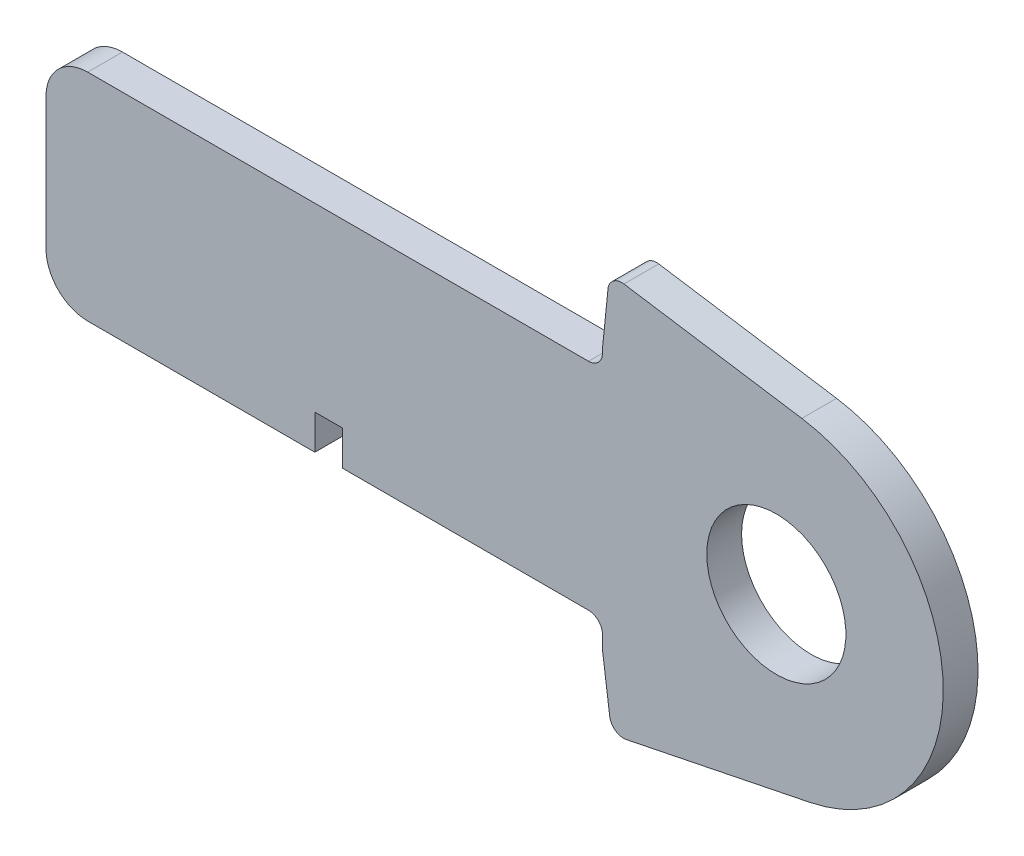
from build123d import *

# Parameters (mm, degrees)
BOSS_EXTRUDE1_DEPTH = 3.175
CUT_EXTRUDE1_DEPTH  = 7.62
SKETCH3_R           = 6.35
CUT_EXTRUDE2_DEPTH  = 7.62
CUT_EXTRUDE3_DEPTH  = 443.627115857
FILLET1_R           = 3.81
FILLET2_R           = 1.27


with BuildPart() as part:
    # Sketch1 → Boss-Extrude1 (new body)
    with BuildSketch(Plane.XY):
        with BuildLine():
            Line((435.33010469, 0.678691456), (439.172882547, -1.614212492))
            Line((439.172882547, -1.614212492), (434.787151486, -0.678691456))
            add(Edge.make_bspline(
                [(0, 0), (0.11179123, -0.527729161), (0.335887463, -1.58561283), (0.94472768, -3.108527015), (1.749889805, -4.572488672), (2.768272335, -5.973609192), (3.993104005, -7.311505618), (5.421679636, -8.587569541), (7.052598221, -9.801114861), (8.883725224, -10.951589231), (10.912400596, -12.040213999), (13.136344152, -13.066312264), (15.553528081, -14.029563428), (18.161318821, -14.928679795), (20.956528242, -15.765030781), (23.936498821, -16.536578215), (27.097842034, -17.244400464), (30.437517266, -17.886690773), (33.951885298, -18.464101669), (37.637295209, -18.976309975), (41.489964184, -19.423636044), (45.506112459, -19.80514129), (49.681767661, -20.121646285), (54.012767863, -20.373360955), (58.494909036, -20.561083494), (63.123897762, -20.684100336), (67.895200479, -20.744329207), (72.804505265, -20.742674403), (77.847009648, -20.678693244), (83.018406129, -20.555920262), (88.313732191, -20.373577887), (93.728207214, -20.133872554), (99.256947275, -19.839216685), (104.89499369, -19.49060908), (110.637384794, -19.089594814), (116.479134607, -18.639389777), (122.414936441, -18.141116951), (128.439613477, -17.597680601), (134.547832047, -17.011801372), (140.734314746, -16.385333349), (146.993600903, -15.721223571), (153.320115485, -15.021624036), (159.708476563, -14.290267097), (166.152848405, -13.528475979), (172.647781594, -12.740600204), (179.187166024, -11.928145018), (185.765533466, -11.094239816), (192.376967293, -10.242811017), (199.015278084, -9.37376151), (205.674882543, -8.493282903), (212.349358377, -7.600650086), (219.032895906, -6.7004538), (225.719308248, -5.795492203), (232.402082768, -4.886043807), (239.075345122, -3.975877517), (245.732904616, -3.06749205), (252.368240069, -2.160970285), (258.975348295, -1.26081803), (265.547576185, -0.366925322), (272.078863439, 0.518895586), (278.562951189, 1.394000598), (284.993721977, 2.257285217), (291.364542133, 3.108203268), (297.66900214, 3.947074317), (303.806375969, 4.748436439), (309.760626579, 5.554962658), (315.551818652, 6.216135275), (321.27090305, 6.780469964), (326.923820465, 7.243146515), (332.503782957, 7.610821489), (338.004397185, 7.886122043), (343.419107553, 8.072891719), (348.74107448, 8.176671364), (353.963650696, 8.200094537), (359.079707468, 8.150631139), (364.082590991, 8.032268225), (368.965318868, 7.850318702), (373.721079318, 7.610921079), (378.343117125, 7.320601554), (382.824493294, 6.983642622), (387.158963185, 6.607910686), (391.339839301, 6.198906082), (395.360701925, 5.761301701), (399.215684034, 5.304267166), (402.898615263, 4.830811549), (406.403955911, 4.348715399), (409.726063296, 3.862864382), (412.859676284, 3.379461168), (415.799871302, 2.903117573), (418.541899149, 2.440155772), (421.081464376, 1.994901374), (423.414160264, 1.571702591), (425.536750687, 1.175899009), (427.445043551, 0.809456817), (429.136486586, 0.478415007), (430.607934716, 0.184234372), (431.857230885, -0.068940506), (432.88219343, -0.280110359), (433.681265576, -0.445808771), (434.252869013, -0.566300363), (434.596385478, -0.637999126), (434.749014267, -0.670556399), (434.787151486, -0.678691456)],
                knots=[0, 0, 0, 0, 0.003638255, 0.007293231, 0.011028136, 0.014901081, 0.018963272, 0.023258475, 0.027820626, 0.032679082, 0.03785316, 0.043361875, 0.049214679, 0.055422346, 0.061988786, 0.068918036, 0.076211157, 0.083868392, 0.091887411, 0.100265912, 0.108999867, 0.118084529, 0.127514843, 0.13728527, 0.147387917, 0.157816481, 0.168563473, 0.179619128, 0.190977373, 0.202626974, 0.214560478, 0.226767249, 0.239236417, 0.251959004, 0.264923894, 0.278119703, 0.291536035, 0.30516028, 0.318980685, 0.332985499, 0.34716279, 0.361498603, 0.375980747, 0.390597192, 0.405332593, 0.420174823, 0.435109533, 0.450124276, 0.465203068, 0.480333154, 0.495500583, 0.510689775, 0.525887334, 0.541078314, 0.556247233, 0.571381785, 0.58646604, 0.601484515, 0.616424329, 0.631269423, 0.646006524, 0.660620684, 0.675098187, 0.689422858, 0.703581825, 0.716907563, 0.730009274, 0.742952128, 0.755725557, 0.768319951, 0.780724337, 0.792926528, 0.804916041, 0.816679084, 0.828203525, 0.8394749, 0.850481359, 0.861207697, 0.871639326, 0.881763414, 0.891563605, 0.901027365, 0.910138977, 0.918883977, 0.927249278, 0.935221104, 0.942784739, 0.949928188, 0.956638465, 0.962904203, 0.968712288, 0.974054485, 0.978918432, 0.983297219, 0.987180246, 0.990560674, 0.993433357, 0.995790626, 0.997629588, 0.998945816, 0.999736592, 1, 1, 1, 1], degree=3))
            add(Edge.make_bspline(
                [(435.33010469, 0.678691456), (435.296755582, 0.699293055), (435.163488681, 0.781619431), (434.863214309, 0.965803828), (434.363194901, 1.272571896), (433.663211466, 1.69979322), (432.763807452, 2.246333125), (431.664530435, 2.908364558), (430.366066728, 3.683736897), (428.86873043, 4.568782589), (427.172675107, 5.559358025), (425.278546429, 6.651449737), (423.186509465, 7.838875427), (420.897374442, 9.116782681), (418.411926851, 10.4790944), (415.730636684, 11.919657082), (412.854464224, 13.43114364), (409.784513475, 15.00705265), (406.521344218, 16.638681918), (403.066494801, 18.319240705), (399.421116368, 20.040349747), (395.586453278, 21.79282696), (391.56470833, 23.569527811), (387.356993489, 25.359407096), (382.965706604, 27.15470981), (378.392717175, 28.945218407), (373.640732922, 30.722778715), (368.711587102, 32.475875028), (363.608964359, 34.196846251), (358.335340013, 35.87451254), (352.894485425, 37.499762392), (347.289561815, 39.062058655), (341.52524157, 40.553388886), (335.605180365, 41.962892679), (329.534395845, 43.28113527), (323.317713598, 44.500180123), (316.960347344, 45.607856696), (310.479914041, 46.603301327), (303.980682286, 47.431342852), (297.494822244, 48.243461645), (291.0186212, 49.006373108), (284.46326746, 49.736966294), (277.835067652, 50.431127833), (271.140596349, 51.086687253), (264.386630807, 51.700815013), (257.580189535, 52.27171033), (250.727858804, 52.796138155), (243.836864005, 53.273290553), (236.914017847, 53.698972807), (229.966694004, 54.072865307), (223.001944897, 54.392360355), (216.027018499, 54.655256617), (209.049321182, 54.859966995), (202.076096041, 55.004530305), (195.114893299, 55.088037667), (188.172953688, 55.108207309), (181.257823923, 55.064678381), (174.376745271, 54.95595632), (167.537272154, 54.780552763), (160.7466557, 54.538140281), (154.012238926, 54.228824112), (147.341395315, 53.850013849), (140.741361553, 53.404123644), (134.219487317, 52.889280335), (127.782938298, 52.305347044), (121.438460058, 51.65475786), (115.193116172, 50.935743156), (109.053599754, 50.150348891), (103.026626206, 49.300114834), (97.118957953, 48.384577869), (91.33692342, 47.406382542), (85.686763085, 46.366529581), (80.174454785, 45.268067638), (74.805999973, 44.111283189), (69.587081438, 42.899646299), (64.52312301, 41.635267927), (59.619568317, 40.320462769), (54.881388132, 38.958385816), (50.313373811, 37.552127128), (45.920850559, 36.103231966), (41.707138151, 34.617193881), (37.677412709, 33.095067788), (33.834761135, 31.541542875), (30.183686712, 29.958740393), (26.726916941, 28.351485511), (23.468364091, 26.721608068), (20.41035055, 25.073674406), (17.555946308, 23.410211446), (14.907899047, 21.73430892), (12.467321746, 20.050217809), (10.237579271, 18.35899521), (8.219437586, 16.664914738), (6.414173801, 14.97055608), (4.824368385, 13.277086383), (3.449964137, 11.587487839), (2.292762263, 9.903098559), (1.352963468, 8.225512409), (0.632693499, 6.555947979), (0.13123808, 4.895344207), (-0.143255259, 3.246152095), (-0.211578297, 1.607049514), (-0.07042072, 0.534882766), (0, 0)],
                knots=[0, 0, 0, 0, 0.00025409, 0.001015373, 0.002283359, 0.004056577, 0.006330982, 0.009105274, 0.012374489, 0.016134023, 0.02037966, 0.025105976, 0.030306237, 0.035972206, 0.042099522, 0.048678064, 0.055701664, 0.063160184, 0.071045824, 0.079349826, 0.08806291, 0.097175756, 0.106678112, 0.116561573, 0.126814275, 0.137428301, 0.148393618, 0.15969976, 0.171338126, 0.183297699, 0.195569604, 0.208143556, 0.221011593, 0.234161831, 0.24758745, 0.261276822, 0.27522271, 0.289414144, 0.303771199, 0.317689227, 0.331784111, 0.346039677, 0.36044387, 0.37498272, 0.389640454, 0.404403316, 0.419256601, 0.434186749, 0.449177265, 0.464214782, 0.479284009, 0.49436974, 0.509457833, 0.524532346, 0.53957932, 0.554582984, 0.569529546, 0.584403417, 0.599190992, 0.613876838, 0.628447475, 0.642888675, 0.657186054, 0.671325546, 0.685294014, 0.699078147, 0.712665095, 0.726042645, 0.739197713, 0.752117586, 0.764792042, 0.777208152, 0.789355685, 0.80122396, 0.812803686, 0.824082909, 0.835054602, 0.845709571, 0.856037853, 0.866033834, 0.875688843, 0.884997719, 0.893953426, 0.902552897, 0.910789386, 0.918660734, 0.926166253, 0.933302626, 0.94007122, 0.94647478, 0.952517526, 0.958204819, 0.963546652, 0.9685566, 0.973249913, 0.977651041, 0.981787043, 0.985694226, 0.989415109, 0.993001157, 0.996508416, 1, 1, 1, 1], degree=3))
        make_face()
    extrude(amount=BOSS_EXTRUDE1_DEPTH)

    # Sketch2 → Cut-Extrude1 (cut)
    with BuildSketch(Plane(origin=(0, 0, 0), x_dir=(-1, 0, 0), z_dir=(0, 0, -1))):
        Polygon((-252.794440989, 13.221493744), (-250.254440989, 13.221493744), (-250.254440989, -2.115243028), (-250.254440989, -3.986349358), (-252.794440989, -3.050796193), (-252.794440989, -2.115243028), align=None)
        Polygon((-159.131940989, 54.422217902), (-159.131940989, 39.039100326), (-152.781940989, 39.039100326), (-152.781940989, 54.422217902), (-152.781940989, 57.645440557), (-159.131940989, 55.540936844), align=None)
        Polygon((-74.994440989, -5.928775484), (-74.994440989, -20.141805429), (-74.994440989, -20.97642061), (-71.819440989, -22.145862066), (-71.819440989, -20.141805429), (-71.819440989, -5.928775484), align=None)
    extrude(amount=-CUT_EXTRUDE1_DEPTH, mode=Mode.SUBTRACT)

    # Sketch3 → Cut-Extrude2 (cut)
    with BuildSketch(Plane(origin=(0, 0, 0), x_dir=(-1, 0, 0), z_dir=(0, 0, -1))):
        with Locations((-292.383806588, 26.255421435)):
            Circle(SKETCH3_R)
    extrude(amount=-CUT_EXTRUDE2_DEPTH, mode=Mode.SUBTRACT)

    # Sketch4 → Cut-Extrude3 (cut, through all)
    with BuildSketch(Plane.XY.offset(3.175)):
        with BuildLine():
            Line((252.794440989, 13.221493744), (252.794440989, -2.10324862))
            add(Edge.make_bspline(
                [(252.794440989, -2.10324862), (254.858559034, -1.821690299), (259.114187798, -1.241934385), (265.547576185, -0.366925322), (272.078863439, 0.518895586), (278.562951189, 1.394000598), (284.993721977, 2.257285217), (291.364542133, 3.108203268), (297.66900214, 3.947074317), (303.806375969, 4.748436439), (309.760626579, 5.554962658), (315.551818652, 6.216135275), (321.27090305, 6.780469964), (326.923820465, 7.243146515), (332.503782957, 7.610821489), (338.004397185, 7.886122043), (343.419107553, 8.072891719), (348.74107448, 8.176671364), (353.963650696, 8.200094537), (359.079707468, 8.150631139), (364.082590991, 8.032268225), (368.965318868, 7.850318702), (373.721079318, 7.610921079), (378.343117125, 7.320601554), (382.824493294, 6.983642622), (387.158963185, 6.607910686), (391.339839301, 6.198906082), (395.360701925, 5.761301701), (399.215684034, 5.304267166), (402.898615263, 4.830811549), (406.403955911, 4.348715399), (409.726063296, 3.862864382), (412.859676284, 3.379461168), (415.799871302, 2.903117573), (418.541899149, 2.440155772), (421.081464376, 1.994901374), (423.414160264, 1.571702591), (425.536750687, 1.175899009), (427.445043551, 0.809456817), (429.136486586, 0.478415007), (430.607934716, 0.184234372), (431.857230885, -0.068940506), (432.88219343, -0.280110359), (433.681265576, -0.445808771), (434.252869013, -0.566300363), (434.596385478, -0.637999126), (434.749014267, -0.670556399), (434.787151486, -0.678691456)],
                knots=[0.58741252, 0.58741252, 0.58741252, 0.58741252, 0.601484515, 0.616424329, 0.631269423, 0.646006524, 0.660620684, 0.675098187, 0.689422858, 0.703581825, 0.716907563, 0.730009274, 0.742952128, 0.755725557, 0.768319951, 0.780724337, 0.792926528, 0.804916041, 0.816679084, 0.828203525, 0.8394749, 0.850481359, 0.861207697, 0.871639326, 0.881763414, 0.891563605, 0.901027365, 0.910138977, 0.918883977, 0.927249278, 0.935221104, 0.942784739, 0.949928188, 0.956638465, 0.962904203, 0.968712288, 0.974054485, 0.978918432, 0.983297219, 0.987180246, 0.990560674, 0.993433357, 0.995790626, 0.997629588, 0.998945816, 0.999736592, 1, 1, 1, 1], degree=3))
            Line((434.787151486, -0.678691456), (439.172882547, -1.614212492))
            Line((439.172882547, -1.614212492), (435.33010469, 0.678691456))
            add(Edge.make_bspline(
                [(435.33010469, 0.678691456), (435.296755582, 0.699293055), (435.163488681, 0.781619431), (434.863214309, 0.965803828), (434.363194901, 1.272571896), (433.663211466, 1.69979322), (432.763807452, 2.246333125), (431.664530435, 2.908364558), (430.366066728, 3.683736897), (428.86873043, 4.568782589), (427.172675107, 5.559358025), (425.278546429, 6.651449737), (423.186509465, 7.838875427), (420.897374442, 9.116782681), (418.411926851, 10.4790944), (415.730636684, 11.919657082), (412.854464224, 13.43114364), (409.784513475, 15.00705265), (406.521344218, 16.638681918), (403.066494801, 18.319240705), (399.421116368, 20.040349747), (395.586453278, 21.79282696), (391.56470833, 23.569527811), (387.356993489, 25.359407096), (382.965706604, 27.15470981), (378.392717175, 28.945218407), (373.640732922, 30.722778715), (368.711587102, 32.475875028), (363.608964359, 34.196846251), (358.335340013, 35.87451254), (352.894485425, 37.499762392), (347.289561815, 39.062058655), (341.52524157, 40.553388886), (335.605180365, 41.962892679), (329.534395845, 43.28113527), (323.317713598, 44.500180123), (316.960347344, 45.607856696), (310.479914041, 46.603301327), (303.980682286, 47.431342852), (297.494822244, 48.243461645), (291.0186212, 49.006373108), (284.46326746, 49.736966294), (277.835067652, 50.431127833), (271.140596349, 51.086687253), (264.386630807, 51.700815013), (257.580189535, 52.27171033), (250.727858804, 52.796138155), (243.836864005, 53.273290553), (236.914017847, 53.698972807), (229.966694004, 54.072865307), (223.001944897, 54.392360355), (216.027018499, 54.655256617), (209.049321182, 54.859966995), (202.076096041, 55.004530305), (195.114893299, 55.088037667), (188.172953688, 55.108207309), (181.257823923, 55.064678381), (174.376745271, 54.95595632), (167.537272154, 54.780552763), (162.460512229, 54.599321798), (159.664388036, 54.481767761), (159.131940989, 54.458728839)],
                knots=[0, 0, 0, 0, 0.00025409, 0.001015373, 0.002283359, 0.004056577, 0.006330982, 0.009105274, 0.012374489, 0.016134023, 0.02037966, 0.025105976, 0.030306237, 0.035972206, 0.042099522, 0.048678064, 0.055701664, 0.063160184, 0.071045824, 0.079349826, 0.08806291, 0.097175756, 0.106678112, 0.116561573, 0.126814275, 0.137428301, 0.148393618, 0.15969976, 0.171338126, 0.183297699, 0.195569604, 0.208143556, 0.221011593, 0.234161831, 0.24758745, 0.261276822, 0.27522271, 0.289414144, 0.303771199, 0.317689227, 0.331784111, 0.346039677, 0.36044387, 0.37498272, 0.389640454, 0.404403316, 0.419256601, 0.434186749, 0.449177265, 0.464214782, 0.479284009, 0.49436974, 0.509457833, 0.524532346, 0.53957932, 0.554582984, 0.569529546, 0.584403417, 0.599190992, 0.613876838, 0.617331371, 0.617331371, 0.617331371, 0.617331371], degree=3))
            Line((159.131940989, 54.458728839), (159.131940989, 39.039100326))
            Line((159.131940989, 39.039100326), (152.781940989, 39.039100326))
            Line((152.781940989, 39.039100326), (152.781940989, 54.152292604))
            add(Edge.make_bspline(
                [(152.781940989, 54.152292604), (150.960838294, 54.055151294), (146.938096683, 53.822767487), (140.741361553, 53.404123644), (134.219487317, 52.889280335), (127.782938298, 52.305347044), (121.438460058, 51.65475786), (115.193116172, 50.935743156), (109.053599754, 50.150348891), (103.026626206, 49.300114834), (97.118957953, 48.384577869), (91.33692342, 47.406382542), (85.686763085, 46.366529581), (80.174454785, 45.268067638), (74.805999973, 44.111283189), (69.587081438, 42.899646299), (64.52312301, 41.635267927), (59.619568317, 40.320462769), (54.881388132, 38.958385816), (50.313373811, 37.552127128), (45.920850559, 36.103231966), (41.707138151, 34.617193881), (37.677412709, 33.095067788), (33.834761135, 31.541542875), (30.183686712, 29.958740393), (26.726916941, 28.351485511), (23.468364091, 26.721608068), (20.41035055, 25.073674406), (17.555946308, 23.410211446), (14.907899047, 21.73430892), (12.467321746, 20.050217809), (10.237579271, 18.35899521), (8.219437586, 16.664914738), (6.414173801, 14.97055608), (4.824368385, 13.277086383), (3.449964137, 11.587487839), (2.292762263, 9.903098559), (1.352963468, 8.225512409), (0.632693499, 6.555947979), (0.13123808, 4.895344207), (-0.143255259, 3.246152095), (-0.211578297, 1.607049514), (-0.07042072, 0.534882766), (0, 0)],
                knots=[0.631067563, 0.631067563, 0.631067563, 0.631067563, 0.642888675, 0.657186054, 0.671325546, 0.685294014, 0.699078147, 0.712665095, 0.726042645, 0.739197713, 0.752117586, 0.764792042, 0.777208152, 0.789355685, 0.80122396, 0.812803686, 0.824082909, 0.835054602, 0.845709571, 0.856037853, 0.866033834, 0.875688843, 0.884997719, 0.893953426, 0.902552897, 0.910789386, 0.918660734, 0.926166253, 0.933302626, 0.94007122, 0.94647478, 0.952517526, 0.958204819, 0.963546652, 0.9685566, 0.973249913, 0.977651041, 0.981787043, 0.985694226, 0.989415109, 0.993001157, 0.996508416, 1, 1, 1, 1], degree=3))
            add(Edge.make_bspline(
                [(0, 0), (0.11179123, -0.527729161), (0.335887463, -1.58561283), (0.94472768, -3.108527015), (1.749889805, -4.572488672), (2.768272335, -5.973609192), (3.993104005, -7.311505618), (5.421679636, -8.587569541), (7.052598221, -9.801114861), (8.883725224, -10.951589231), (10.912400596, -12.040213999), (13.136344152, -13.066312264), (15.553528081, -14.029563428), (18.161318821, -14.928679795), (20.956528242, -15.765030781), (23.936498821, -16.536578215), (27.097842034, -17.244400464), (30.437517266, -17.886690773), (33.951885298, -18.464101669), (37.637295209, -18.976309975), (41.489964184, -19.423636044), (45.506112459, -19.80514129), (49.681767661, -20.121646285), (54.012767863, -20.373360955), (58.494909036, -20.561083494), (63.123897762, -20.684100336), (67.581814032, -20.740373283), (70.496154942, -20.74305812), (71.819440989, -20.73766124)],
                knots=[0, 0, 0, 0, 0.003638255, 0.007293231, 0.011028136, 0.014901081, 0.018963272, 0.023258475, 0.027820626, 0.032679082, 0.03785316, 0.043361875, 0.049214679, 0.055422346, 0.061988786, 0.068918036, 0.076211157, 0.083868392, 0.091887411, 0.100265912, 0.108999867, 0.118084529, 0.127514843, 0.13728527, 0.147387917, 0.157816481, 0.168563473, 0.177502133, 0.177502133, 0.177502133, 0.177502133], degree=3))
            Line((71.819440989, -20.73766124), (71.819440989, -5.928775484))
            Line((71.819440989, -5.928775484), (74.994440989, -5.928775484))
            Line((74.994440989, -5.928775484), (74.994440989, -20.712271676))
            add(Edge.make_bspline(
                [(74.994440989, -20.712271676), (75.930905335, -20.70120515), (78.59177595, -20.661011912), (83.018406129, -20.555920262), (88.313732191, -20.373577887), (93.728207214, -20.133872554), (99.256947275, -19.839216685), (104.89499369, -19.49060908), (110.637384794, -19.089594814), (116.479134607, -18.639389777), (122.414936441, -18.141116951), (128.439613477, -17.597680601), (134.547832047, -17.011801372), (140.734314746, -16.385333349), (146.993600903, -15.721223571), (153.320115485, -15.021624036), (159.708476563, -14.290267097), (166.152848405, -13.528475979), (172.647781594, -12.740600204), (179.187166024, -11.928145018), (185.765533466, -11.094239816), (192.376967293, -10.242811017), (199.015278084, -9.37376151), (205.674882543, -8.493282903), (212.349358377, -7.600650086), (219.032895906, -6.7004538), (225.719308248, -5.795492203), (232.402082768, -4.886043807), (239.075345122, -3.975877517), (245.025066378, -3.164072481), (248.749707349, -2.655315536), (250.254440989, -2.449884512)],
                knots=[0.184651258, 0.184651258, 0.184651258, 0.184651258, 0.190977373, 0.202626974, 0.214560478, 0.226767249, 0.239236417, 0.251959004, 0.264923894, 0.278119703, 0.291536035, 0.30516028, 0.318980685, 0.332985499, 0.34716279, 0.361498603, 0.375980747, 0.390597192, 0.405332593, 0.420174823, 0.435109533, 0.450124276, 0.465203068, 0.480333154, 0.495500583, 0.510689775, 0.525887334, 0.541078314, 0.556247233, 0.571381785, 0.581640373, 0.581640373, 0.581640373, 0.581640373], degree=3))
            Line((250.254440989, -2.449884512), (250.254440989, 13.221493744))
            Line((250.254440989, 13.221493744), (252.794440989, 13.221493744))
        make_face()
        with BuildLine():
            Line((276.508806588, 37.713859181), (277.148087148, 44.028344676))
            Line((277.148087148, 44.028344676), (294.709258182, 41.316957707))
            ThreePointArc((294.709258182, 41.316957707), (307.619460539, 26.619356431), (295.425747266, 11.32209639))
            Line((295.425747266, 11.32209639), (277.355482442, 7.64115638))
            Line((277.355482442, 7.64115638), (276.508806588, 13.934637567))
            Line((276.508806588, 13.934637567), (276.508806588, 16.412921435))
            Line((276.508806588, 16.412921435), (252.794440989, 16.412921435))
            Line((252.794440989, 16.412921435), (252.794440989, 19.587921435))
            Line((252.794440989, 19.587921435), (250.254440989, 19.587921435))
            Line((250.254440989, 19.587921435), (250.254440989, 16.412921435))
            Line((250.254440989, 16.412921435), (225.708806588, 16.412921435))
            Line((225.708806588, 16.412921435), (225.708806588, 36.097921435))
            Line((225.708806588, 36.097921435), (276.508806588, 36.097921435))
            Line((276.508806588, 36.097921435), (276.508806588, 37.713859181))
        make_face(mode=Mode.SUBTRACT)
    extrude(amount=-CUT_EXTRUDE3_DEPTH, mode=Mode.SUBTRACT)

    # Fillet1
    fillet1_edges = [part.edges().sort_by_distance(p)[0] for p in [
        (225.708806588, 36.097921435, 1.5875),
        (225.708806588, 16.412921435, 1.5875),
    ]]
    fillet(fillet1_edges, radius=FILLET1_R)

    # Fillet2
    fillet2_edges = [part.edges().sort_by_distance(p)[0] for p in [
        (277.355482442, 7.64115638, 1.5875),
        (277.148087148, 44.028344676, 1.5875),
        (276.508806588, 36.097921435, 1.5875),
        (276.508806588, 16.412921435, 1.5875),
    ]]
    fillet(fillet2_edges, radius=FILLET2_R)


solid = part.part
